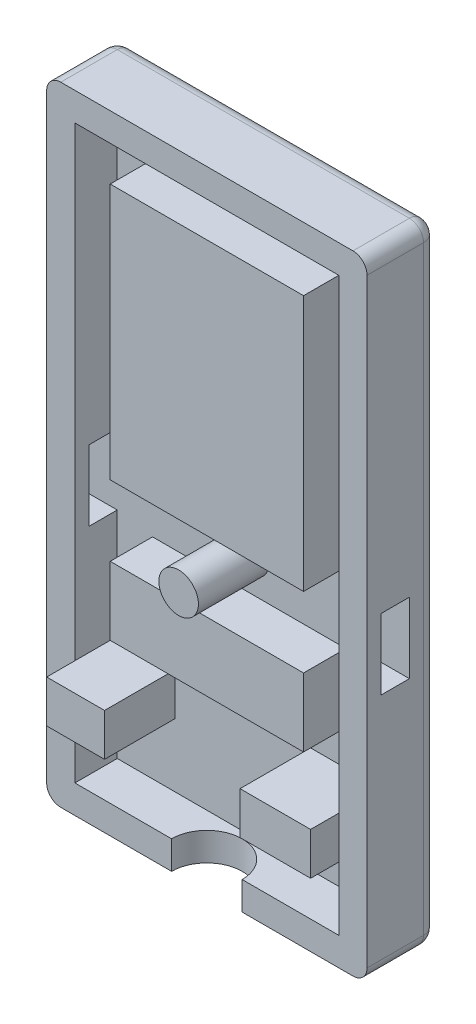
from build123d import *

# Parameters (mm, degrees)
SKETCH1_W           = 22.7
SKETCH1_H           = 44.5
BOSS_EXTRUDE1_DEPTH = 2
SKETCH2_W           = 22.7
SKETCH2_H           = 44.5
SKETCH2_W_2         = 18.7
SKETCH2_H_2         = 40.5
BOSS_EXTRUDE2_DEPTH = 3
SKETCH3_W           = 5
SKETCH3_H           = 3
SKETCH3_W_2         = 4.1
SKETCH3_R           = 1.4
BOSS_EXTRUDE3_DEPTH = 5
SKETCH4_W           = 2
SKETCH4_H           = 5
CUT_EXTRUDE1_DEPTH  = 3
CUT_EXTRUDE2_DEPTH  = 3
FILLET2_R           = 1
SKETCH12_W          = 13.7
SKETCH12_H          = 18.15
SKETCH12_H_2        = 4.85
BOSS_EXTRUDE8_DEPTH = 3
CUT_EXTRUDE3_DEPTH  = 3


with BuildPart() as part:
    # Sketch1 → Boss-Extrude1 (new body)
    with BuildSketch(Plane.XY):
        Rectangle(SKETCH1_W, SKETCH1_H)
    extrude(amount=BOSS_EXTRUDE1_DEPTH)

    # Sketch2 → Boss-Extrude2 (add)
    with BuildSketch(Plane.XY.offset(2)):
        Rectangle(SKETCH2_W, SKETCH2_H)
        Rectangle(SKETCH2_W_2, SKETCH2_H_2, mode=Mode.SUBTRACT)
    extrude(amount=BOSS_EXTRUDE2_DEPTH)

    # Sketch3 → Boss-Extrude3 (add)
    with BuildSketch(Plane.XY.offset(2)):
        with Locations((6.85, -14.25)):
            Rectangle(SKETCH3_W, SKETCH3_H)
        with Locations((-7.3, -14.25)):
            Rectangle(SKETCH3_W_2, SKETCH3_H)
        with Locations((0, -2.9)):
            Circle(SKETCH3_R)
    extrude(amount=BOSS_EXTRUDE3_DEPTH)

    # Sketch4 → Cut-Extrude1 (cut, through all)
    with BuildSketch(Plane(origin=(-9.35, 0, 0), x_dir=(0, 0, -1), z_dir=(1, 0, 0))):
        with Locations((-3, -2.5)):
            Rectangle(SKETCH4_W, SKETCH4_H)
    extrude(amount=-CUT_EXTRUDE1_DEPTH, mode=Mode.SUBTRACT)

    # Sketch8 → Cut-Extrude2 (cut, through all)
    with BuildSketch(Plane.ZY.offset(-9.35)):
        Polygon((2, 0), (2, -2.5), (2, -5), (4, -5), (4, -2.5), (4, 0), align=None)
    extrude(amount=-CUT_EXTRUDE2_DEPTH, mode=Mode.SUBTRACT)

    # Fillet2
    fillet2_edges = [part.edges().sort_by_distance(p)[0] for p in [
        (0, -22.25, 0),
        (-11.35, 0, 0),
        (0, 22.25, 0),
        (11.35, 0, 0),
        (11.35, -22.25, 2.5),
        (-11.35, -22.25, 2.5),
        (-11.35, 22.25, 2.5),
        (11.35, 22.25, 2.5),
    ]]
    fillet(fillet2_edges, radius=FILLET2_R)

    # Sketch12 → Boss-Extrude8 (add)
    with BuildSketch(Plane.XY.offset(2)):
        with Locations((0, 8.675)):
            Rectangle(SKETCH12_W, SKETCH12_H)
        with Locations((0, -7.825)):
            Rectangle(SKETCH12_W, SKETCH12_H_2)
    extrude(amount=BOSS_EXTRUDE8_DEPTH)

    # Sketch13 → Cut-Extrude3 (cut, through all)
    with BuildSketch(Plane(origin=(0, -20.25, 0), x_dir=(1, 0, 0), z_dir=(0, 1, 0))):
        with BuildLine():
            Line((-2.5, -5), (2.5, -5))
            ThreePointArc((2.5, -5), (0, -2.5), (-2.5, -5))
        make_face()
    extrude(amount=-CUT_EXTRUDE3_DEPTH, mode=Mode.SUBTRACT)


solid = part.part
